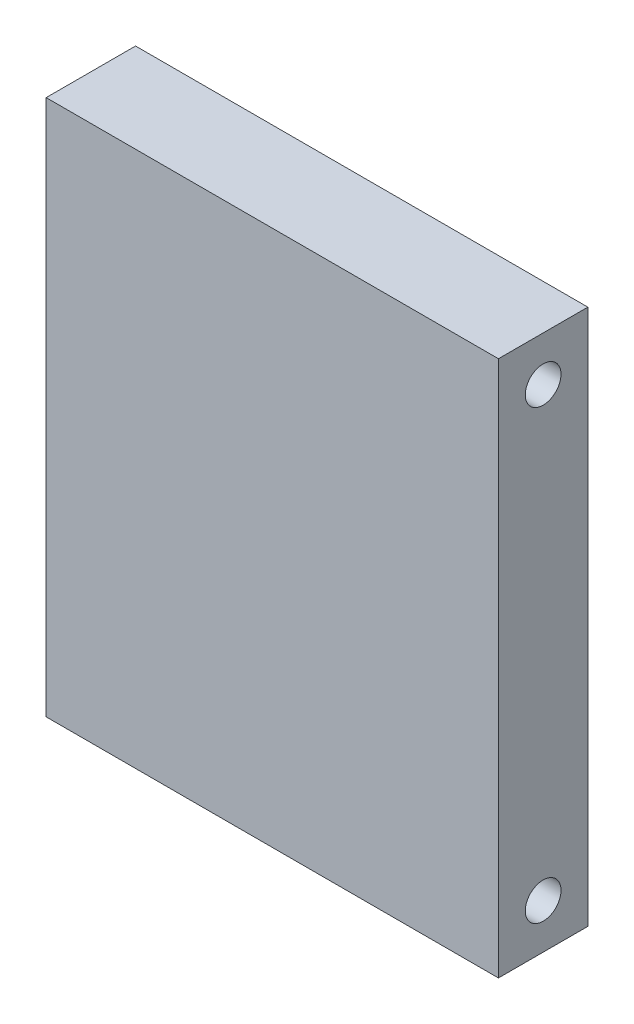
from build123d import *

# Parameters (mm, degrees)
SKETCH1_W          = 50.6
SKETCH1_H          = 60
EXTRUDE1_DEPTH     = 10
SKETCH2_R          = 2
CUT_EXTRUDE1_DEPTH = 50.6


with BuildPart() as part:
    # Sketch1 → Extrude1 (new body)
    with BuildSketch(Plane.XY):
        with Locations((25.3, 30)):
            Rectangle(SKETCH1_W, SKETCH1_H)
    extrude(amount=EXTRUDE1_DEPTH)

    # Sketch2 → Cut-Extrude1 (cut)
    with BuildSketch(Plane.ZY):
        with Locations((5, 55)):
            Circle(SKETCH2_R)
        with Locations((5, 5)):
            Circle(SKETCH2_R)
    extrude(amount=-CUT_EXTRUDE1_DEPTH, mode=Mode.SUBTRACT)


solid = part.part
